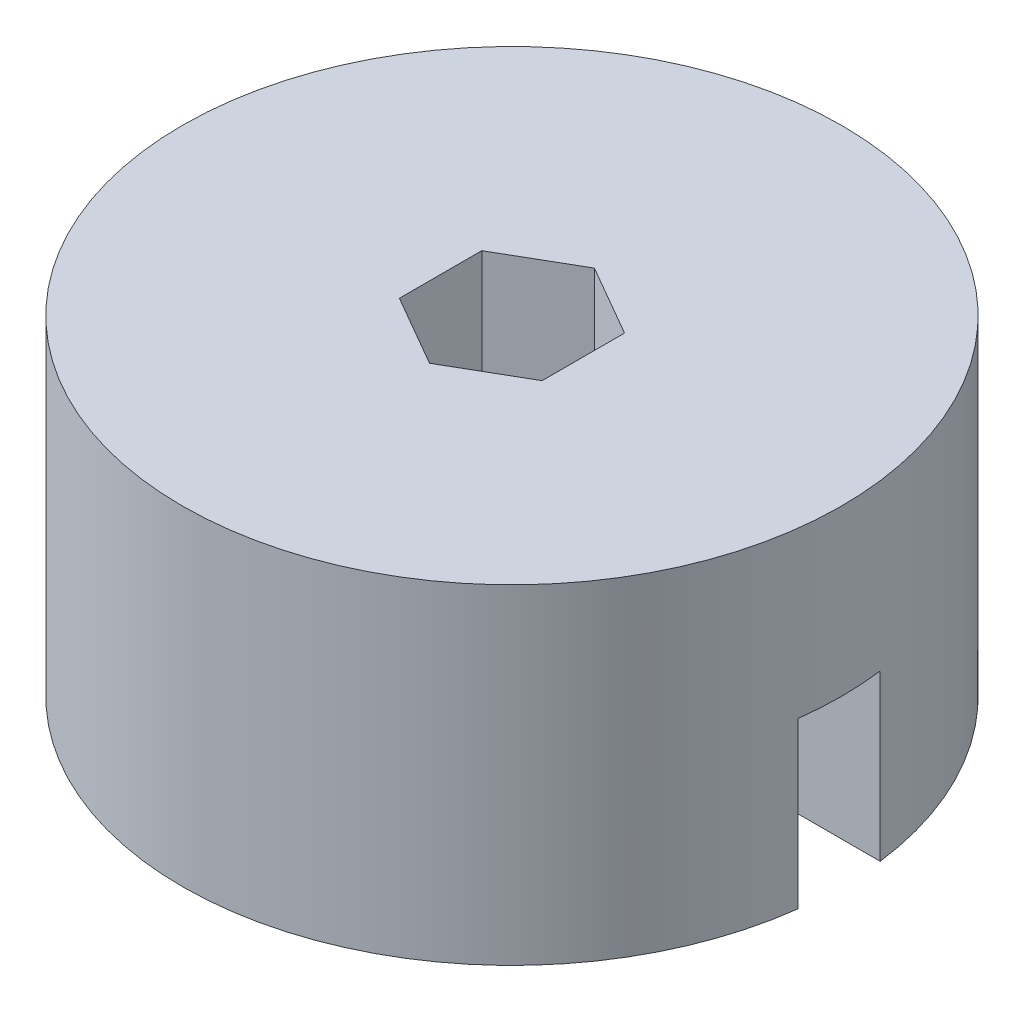
from build123d import *

# Parameters (mm, degrees)
SKETCH1_R           = 25.4
BOSS_EXTRUDE1_DEPTH = 25.4
CUT_EXTRUDE1_DEPTH  = 12.7


with BuildPart() as part:
    # Sketch1 → Boss-Extrude1 (new body)
    with BuildSketch(Plane(origin=(0, 0, 0), x_dir=(1, 0, 0), z_dir=(0, 1, 0))):
        Circle(SKETCH1_R)
        Polygon((0, 6.35), (5.499261314, 3.175), (5.499261314, -3.175), (0, -6.35), (-5.499261314, -3.175), (-5.499261314, 3.175), align=None, mode=Mode.SUBTRACT)
    extrude(amount=BOSS_EXTRUDE1_DEPTH)

    # Sketch1_4 → Cut-Extrude1 (cut)
    with BuildSketch(Plane(origin=(0, 0, 0), x_dir=(1, 0, 0), z_dir=(0, 1, 0))):
        with BuildLine():
            Line((25.200781238, 3.175), (5.499261314, 3.175))
            Line((5.499261314, 3.175), (5.499261314, -3.175))
            Line((5.499261314, -3.175), (25.200781238, -3.175))
            ThreePointArc((25.200781238, -3.175), (25.350146385, -1.590621979), (25.4, 0))
            ThreePointArc((25.4, 0), (25.350146385, 1.590621979), (25.200781238, 3.175))
        make_face()
    extrude(amount=CUT_EXTRUDE1_DEPTH, mode=Mode.SUBTRACT)


solid = part.part
